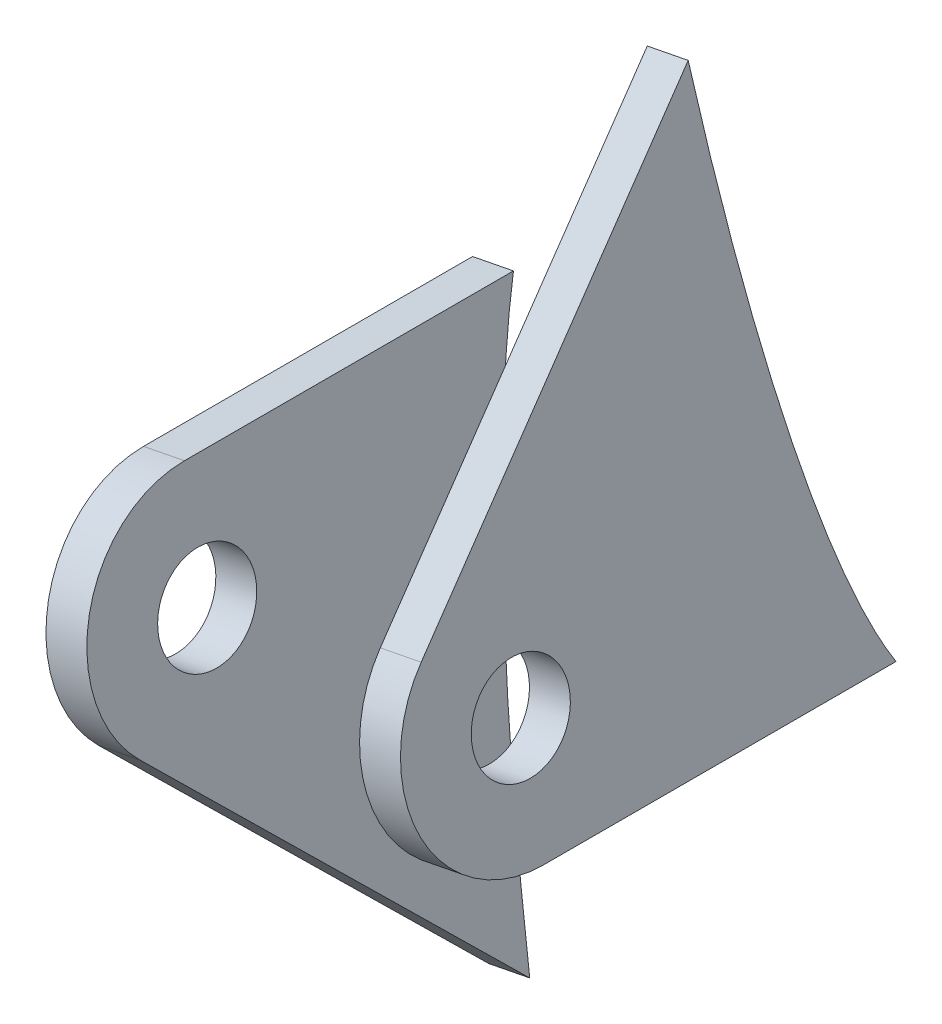
from build123d import *

# Parameters (mm, degrees)
SZKIC1_R                    = 3.5
DODANIE_WYCI_GNI_CIE1_DEPTH = 3
SZKIC2_R                    = 3.5
DODANIE_WYCI_GNI_CIE2_DEPTH = 3


with BuildPart() as part:
    # Szkic1 → Dodanie-wyciągnięcie1 (new body)
    with BuildSketch(Plane(origin=(1360.627920947, 266.553908411, 0.452649646), x_dir=(-0.000320381, -6.2764e-05, 0.999999947), z_dir=(-0.981345807, -0.192250619, -0.000326471))):
        with BuildLine():
            Line((408.64068808, -370.941776368), (433.992356241, -370.941776368))
            ThreePointArc((433.992356241, -370.941776368), (441.845332267, -365.694585543), (440.002763881, -356.431368728))
            Line((440.002763881, -356.431368728), (416.229122465, -332.657727312))
            add(Edge.make_bspline(
                [(416.229122465, -332.657727312), (414.804252129, -352.119194686), (411.949104367, -364.983138219), (408.64068808, -370.941776368)],
                knots=[0.296030426, 0.296030426, 0.296030426, 0.296030426, 0.428007656, 0.428007656, 0.428007656, 0.428007656], degree=3, weights=[0.516950401, 0.549350231, 0.628198033, 0.753493806]))
        make_face()
        with Locations((433.992356241, -362.441776368)):
            Circle(SZKIC1_R, mode=Mode.SUBTRACT)
    extrude(amount=-DODANIE_WYCI_GNI_CIE1_DEPTH)


with BuildPart() as body_2:
    # Szkic2 → Dodanie-wyciągnięcie2 (new body)
    with BuildSketch(Plane(origin=(1341.001004808, 262.708896026, 0.446120222), x_dir=(0.000320381, 6.2764e-05, -0.999999947), z_dir=(0.981345807, 0.192250619, 0.000326471))):
        with BuildLine():
            ThreePointArc((-433.992356241, -353.941776368), (-441.845332267, -359.188967193), (-440.002763881, -368.452184008))
            Line((-440.002763881, -368.452184008), (-416.470812313, -391.984135576))
            add(Edge.make_bspline(
                [(-416.470812313, -391.984135576), (-415.438117523, -375.017376477), (-413.241019551, -361.835375789), (-410.330956854, -353.941776368)],
                knots=[0.231951537, 0.231951537, 0.231951537, 0.231951537, 0.385696539, 0.385696539, 0.385696539, 0.385696539], degree=3, weights=[0.697863065, 0.688873406, 0.718172745, 0.785761082]))
            Line((-410.330956854, -353.941776368), (-433.992356241, -353.941776368))
        make_face()
        with Locations((-433.992356241, -362.441776368)):
            Circle(SZKIC2_R, mode=Mode.SUBTRACT)
    extrude(amount=-DODANIE_WYCI_GNI_CIE2_DEPTH)


solid = Compound([part.part, body_2.part])
